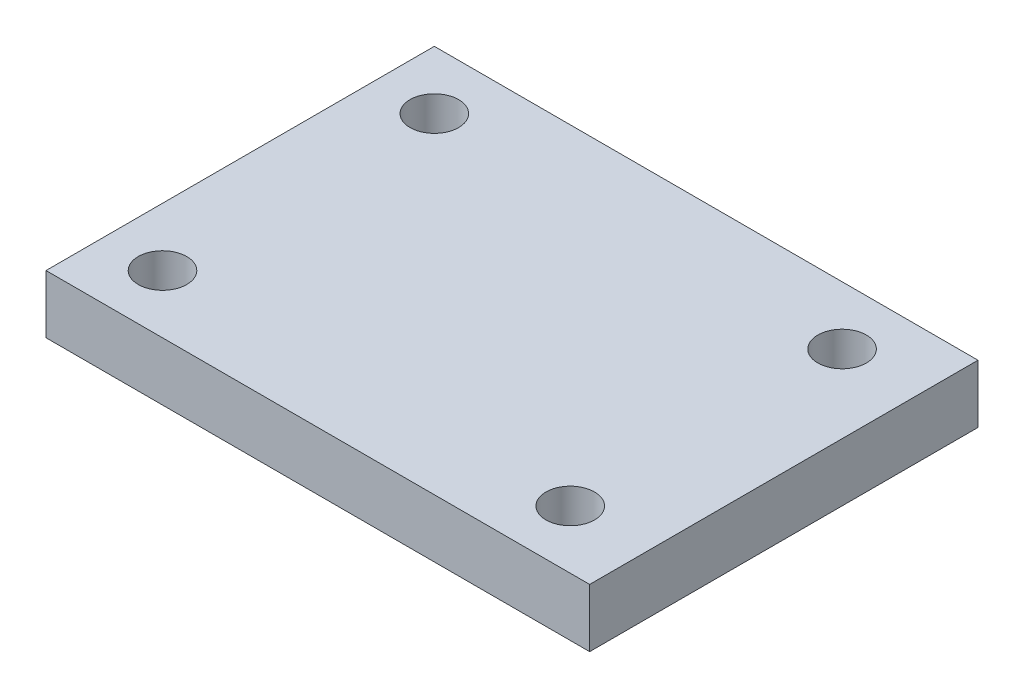
from build123d import *

# Parameters (mm, degrees)
SKETCH_1_W        = 28
SKETCH_1_H        = 20
EXTRUDE_1_DEPTH   = 3
HOLE_WIZARD_M31_D = 2.5


with BuildPart() as part:
    # Эскиз1 → Бобышка-Вытянуть1 (new body)
    with BuildSketch(Plane(origin=(0, 0, 0), x_dir=(1, 0, 0), z_dir=(0, 1, 0))):
        with Locations((14, 10)):
            Rectangle(SKETCH_1_W, SKETCH_1_H)
    extrude(amount=EXTRUDE_1_DEPTH)

    # Отверстие обработанное метчиком M31 (through all)
    with Locations(Plane(origin=(0, 3, 0), x_dir=(1, 0, 0), z_dir=(0, 1, 0))):
        with Locations((3, 17), (3, 3), (24, 3), (24, 17)):
            Hole(HOLE_WIZARD_M31_D / 2)


solid = part.part
